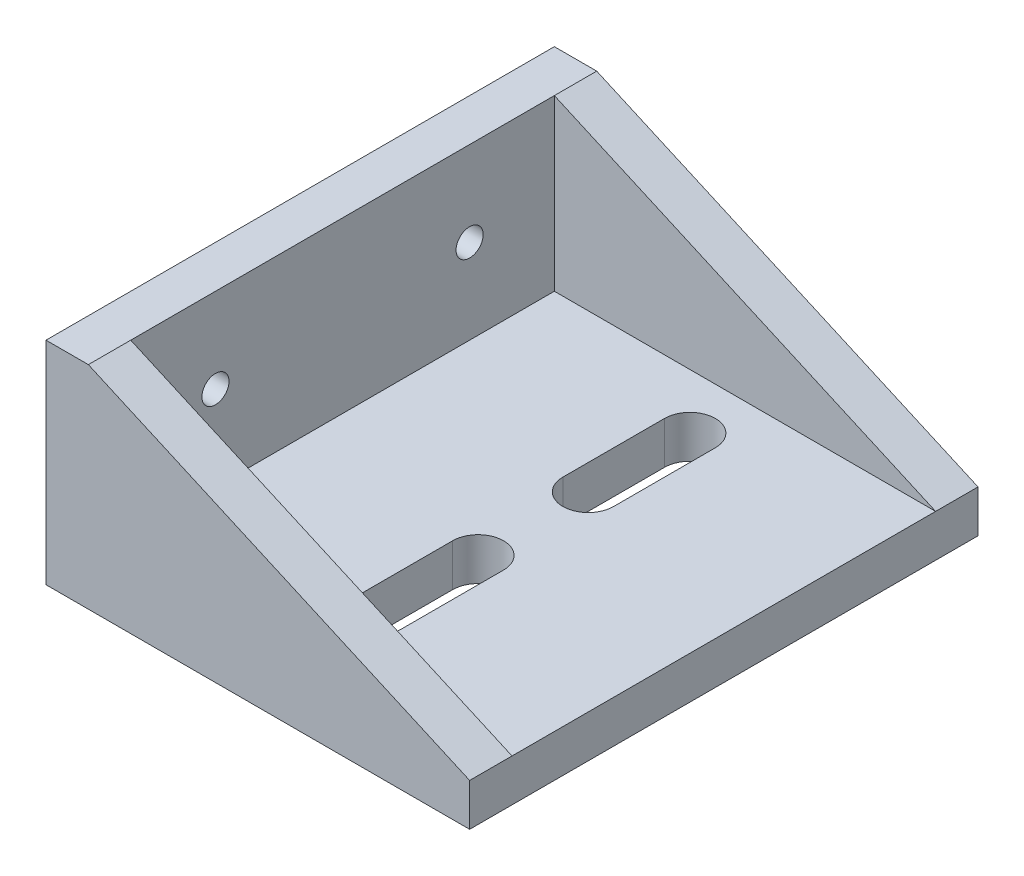
from build123d import *

# Parameters (mm, degrees)
BOSS_EXTRUDE1_DEPTH = 60
BOSS_EXTRUDE2_DEPTH = 5
BOSS_EXTRUDE3_DEPTH = 5
SKETCH4_R           = 1.6
CUT_EXTRUDE1_DEPTH  = 5
CUT_EXTRUDE2_DEPTH  = 5


with BuildPart() as part:
    # Sketch1 → Boss-Extrude1 (new body)
    with BuildSketch(Plane.XY):
        Polygon((0, 0), (-50, 0), (-50, 25), (-45, 25), (-45, 5), (0, 5), align=None)
    extrude(amount=BOSS_EXTRUDE1_DEPTH)

    # Sketch2 → Boss-Extrude2 (add)
    with BuildSketch(Plane.XY.offset(60)):
        Polygon((-45, 25), (0, 5), (-45, 5), align=None)
    extrude(amount=-BOSS_EXTRUDE2_DEPTH)

    # Sketch3 → Boss-Extrude3 (add)
    with BuildSketch(Plane(origin=(0, 0, 0), x_dir=(-1, 0, 0), z_dir=(0, 0, -1))):
        Polygon((45, 25), (0, 5), (45, 5), align=None)
    extrude(amount=-BOSS_EXTRUDE3_DEPTH)

    # Sketch4 → Cut-Extrude1 (cut)
    with BuildSketch(Plane(origin=(-45, 0, 0), x_dir=(0, 0, -1), z_dir=(1, 0, 0))):
        with Locations((-45, 15)):
            Circle(SKETCH4_R)
        with Locations((-15, 15)):
            Circle(SKETCH4_R)
    extrude(amount=-CUT_EXTRUDE1_DEPTH, mode=Mode.SUBTRACT)

    # Sketch5 → Cut-Extrude2 (cut)
    with BuildSketch(Plane(origin=(0, 5, 0), x_dir=(1, 0, 0), z_dir=(0, 1, 0))):
        with BuildLine():
            Line((-25.5, -23.5), (-25.5, -11.5))
            ThreePointArc((-25.5, -11.5), (-22.5, -8.5), (-19.5, -11.5))
            Line((-19.5, -11.5), (-19.5, -23.5))
            ThreePointArc((-19.5, -23.5), (-22.5, -26.5), (-25.5, -23.5))
        make_face()
        with BuildLine():
            Line((-19.5, -48.5), (-19.5, -36.5))
            ThreePointArc((-19.5, -36.5), (-22.5, -33.5), (-25.5, -36.5))
            Line((-25.5, -36.5), (-25.5, -48.5))
            ThreePointArc((-25.5, -48.5), (-22.5, -51.5), (-19.5, -48.5))
        make_face()
    extrude(amount=-CUT_EXTRUDE2_DEPTH, mode=Mode.SUBTRACT)


solid = part.part
